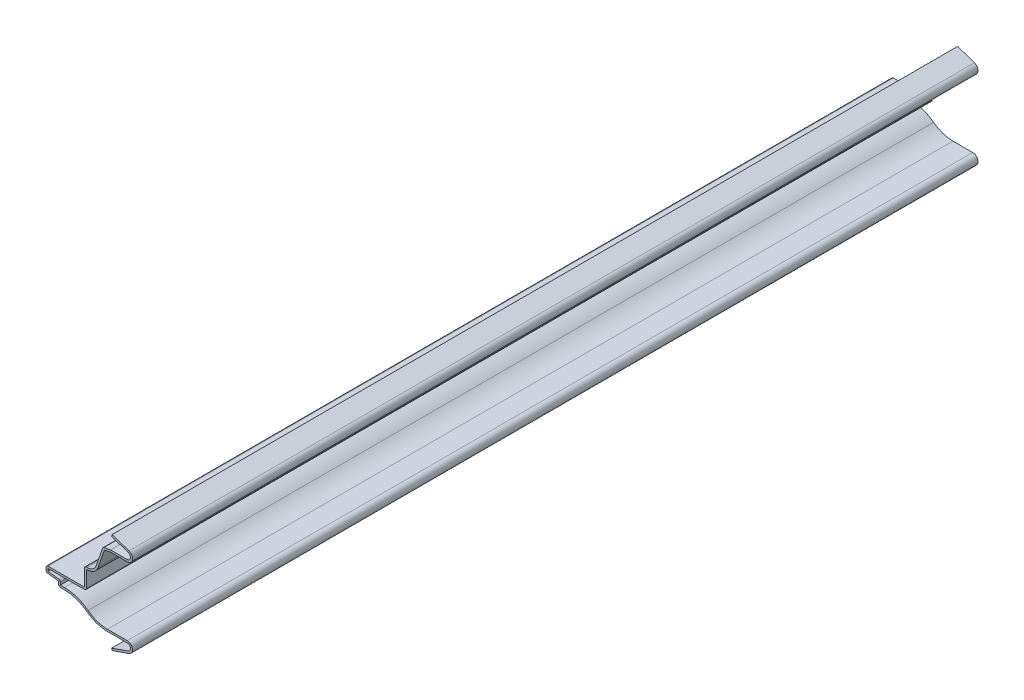
from build123d import *

# Parameters (mm, degrees)
EXTRUDE_THIN1_DEPTH = 436.5625
FILLET1_R           = 1.016


with BuildPart() as part:
    # Sketch1 → Extrude-Thin1 (new body)
    with BuildSketch(Plane.XY):
        with BuildLine():
            Line((9.781263434, 50.00625), (1.15875723, 47.010410758))
            ThreePointArc((1.15875723, 47.010410758), (0.024053154, 45.094051318), (1.724851264, 43.65625))
            Line((1.724851264, 43.65625), (10.31875, 43.65625))
            Line((10.31875, 43.65625), (14.273529908, 42.8625))
            Line((14.273529908, 42.8625), (17.712331019, 32.965078439))
            ThreePointArc((17.712331019, 32.965078439), (19.450830911, 30.647054561), (22.211029908, 29.765625))
            Line((22.211029908, 29.765625), (23.798529908, 29.765625))
            Line((23.798529908, 29.765625), (23.798529908, 20.240625))
            Line((23.798529908, 20.240625), (43.65625, 20.240625))
            Line((43.65625, 20.240625), (43.65625, 17.065625))
            Line((43.65625, 17.065625), (37.30625, 16.271875))
            Line((37.30625, 16.271875), (37.30625, 13.890625))
            Line((37.30625, 13.890625), (34.13125, 13.890625))
            ThreePointArc((34.13125, 13.890625), (28.010554633, 12.880569241), (22.538913712, 9.957510902))
            ThreePointArc((22.538913712, 9.957510902), (17.520243065, 7.276438204), (11.90625, 6.35))
            Line((11.90625, 6.35), (10.31875, 6.35))
            Line((10.31875, 6.35), (1.724851264, 6.35))
            ThreePointArc((1.724851264, 6.35), (0.024053154, 4.912198682), (1.15875723, 2.995839242))
            Line((1.15875723, 2.995839242), (9.781263434, 0))
            Line((9.781263434, 0), (9.447813501, -0.95972243))
            Line((9.447813501, -0.95972243), (0.825307297, 2.036116813))
            ThreePointArc((0.825307297, 2.036116813), (-0.977778666, 5.081281519), (1.724851264, 7.366))
            Line((1.724851264, 7.366), (10.31875, 7.366))
            Line((10.31875, 7.366), (11.90625, 7.366))
            ThreePointArc((11.90625, 7.366), (17.193805978, 8.238568564), (21.920655776, 10.763744817))
            ThreePointArc((21.920655776, 10.763744817), (27.684117546, 13.842699601), (34.13125, 14.906625))
            Line((34.13125, 14.906625), (36.29025, 14.906625))
            Line((36.29025, 14.906625), (36.29025, 17.168781734))
            Line((36.29025, 17.168781734), (42.64025, 17.962531734))
            Line((42.64025, 17.962531734), (42.64025, 19.224625))
            Line((42.64025, 19.224625), (22.782529908, 19.224625))
            Line((22.782529908, 19.224625), (22.782529908, 28.749625))
            Line((22.782529908, 28.749625), (22.211029908, 28.749625))
            ThreePointArc((22.211029908, 28.749625), (18.861988459, 29.819092868), (16.752608589, 32.631628506))
            Line((16.752608589, 32.631628506), (13.504357649, 41.98061609))
            Line((13.504357649, 41.98061609), (10.217797732, 42.64025))
            Line((10.217797732, 42.64025), (1.724851264, 42.64025))
            ThreePointArc((1.724851264, 42.64025), (-0.977778666, 44.924968481), (0.825307297, 47.970133187))
            Line((0.825307297, 47.970133187), (9.447813501, 50.96597243))
            Line((9.447813501, 50.96597243), (9.781263434, 50.00625))
        make_face()
    extrude(amount=-EXTRUDE_THIN1_DEPTH)

    # Fillet1
    fillet1_edges = [part.edges().sort_by_distance(p)[0] for p in [
        (36.29025, 17.168781734, -218.28125),
        (22.782529908, 19.224625, -218.28125),
        (10.31875, 43.65625, -218.28125),
        (14.273529908, 42.8625, -218.28125),
        (23.798529908, 29.765625, -218.28125),
        (43.65625, 20.240625, -218.28125),
        (43.65625, 17.065625, -218.28125),
        (37.30625, 13.890625, -218.28125),
    ]]
    fillet(fillet1_edges, radius=FILLET1_R)


with BuildPart() as body_2:
    # Mirror1: mirrored copy
    add(part.part.mirror(Plane(origin=(0, 0, 0), x_dir=(0, 0, 1), z_dir=(1, 0, 0))))


solid = body_2.part
